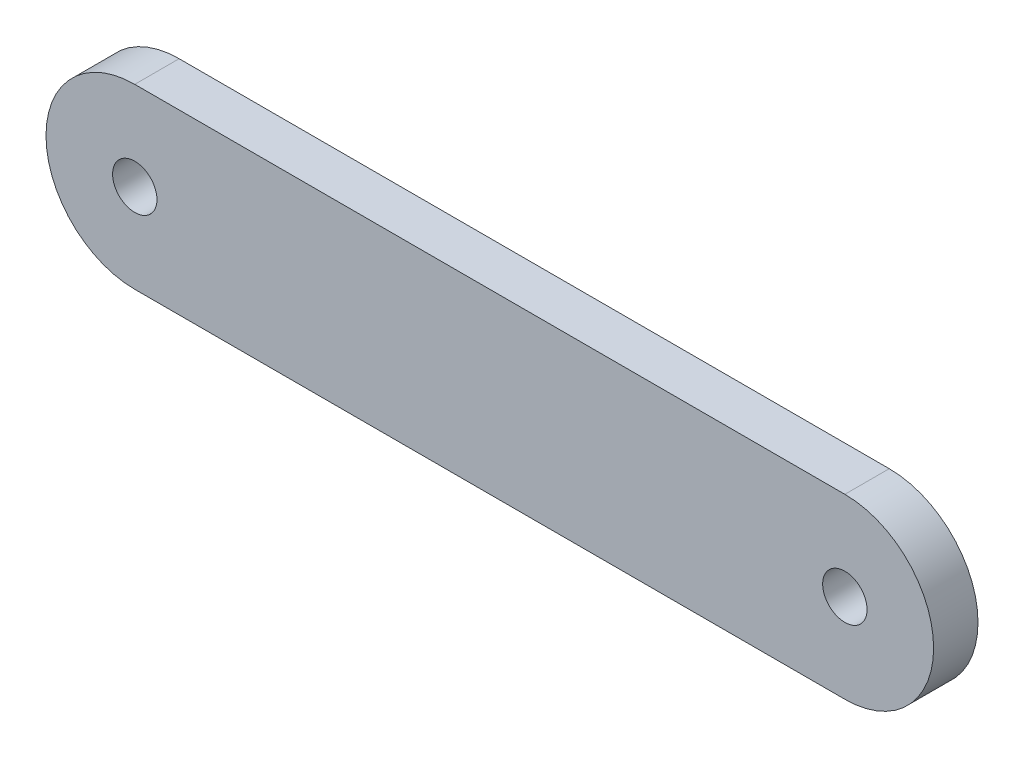
from build123d import *

# Parameters (mm, degrees)
SKETCH1_R           = 1.5875
BOSS_EXTRUDE1_DEPTH = 3.175


with BuildPart() as part:
    # Sketch1 → Boss-Extrude1 (new body)
    with BuildSketch(Plane.XY):
        with BuildLine():
            Line((-48.768, 26.416), (2.032, 26.416))
            ThreePointArc((2.032, 26.416), (8.382, 20.066), (2.032, 13.716))
            Line((2.032, 13.716), (-48.768, 13.716))
            ThreePointArc((-48.768, 13.716), (-55.118, 20.066), (-48.768, 26.416))
        make_face()
        with Locations((-48.768, 20.066)):
            Circle(SKETCH1_R, mode=Mode.SUBTRACT)
        with Locations((2.032, 20.066)):
            Circle(SKETCH1_R, mode=Mode.SUBTRACT)
    extrude(amount=BOSS_EXTRUDE1_DEPTH)


solid = part.part
